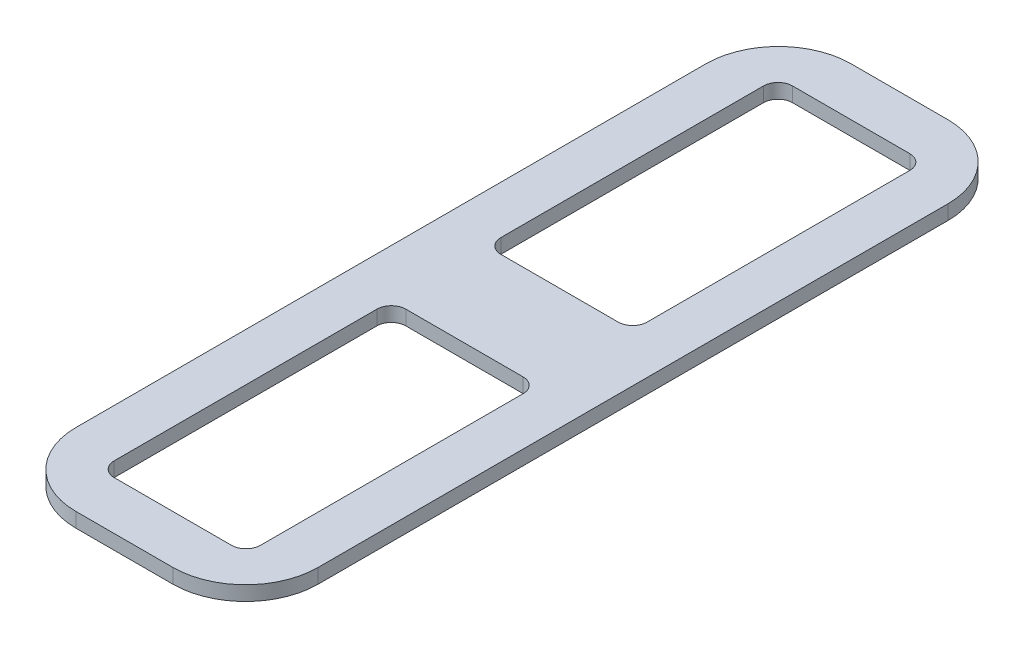
from build123d import *

# Parameters (mm, degrees)
SKETCH1_W           = 50
SKETCH1_H           = 160
BOSS_EXTRUDE1_DEPTH = 3
FILLET2_R           = 15
CUT_EXTRUDE1_DEPTH  = 4


with BuildPart() as part:
    # Sketch1 → Boss-Extrude1 (new body)
    with BuildSketch(Plane(origin=(0, 0, 0), x_dir=(1, 0, 0), z_dir=(0, 1, 0))):
        Rectangle(SKETCH1_W, SKETCH1_H)
    extrude(amount=BOSS_EXTRUDE1_DEPTH)

    # Fillet2
    fillet2_edges = [part.edges().sort_by_distance(p)[0] for p in [
        (25, 1.5, 80),
        (-25, 1.5, 80),
        (-25, 1.5, -80),
        (25, 1.5, -80),
    ]]
    fillet(fillet2_edges, radius=FILLET2_R)

    # Sketch3 → Cut-Extrude1 (cut, through all)
    with BuildSketch(Plane(origin=(0, 3, 0), x_dir=(1, 0, 0), z_dir=(0, 1, 0))):
        with BuildLine():
            Line((-12.1, 70), (12.1, 70))
            ThreePointArc((12.1, 70), (14.221320344, 69.121320344), (15.1, 67))
            Line((15.1, 67), (15.1, 12.8))
            ThreePointArc((15.1, 12.8), (14.221320344, 10.678679656), (12.1, 9.8))
            Line((12.1, 9.8), (-12.1, 9.8))
            ThreePointArc((-12.1, 9.8), (-14.221320344, 10.678679656), (-15.1, 12.8))
            Line((-15.1, 12.8), (-15.1, 67))
            ThreePointArc((-15.1, 67), (-14.221320344, 69.121320344), (-12.1, 70))
        make_face()
    cut_extrude1 = extrude(amount=-CUT_EXTRUDE1_DEPTH, mode=Mode.SUBTRACT)

    # Mirror1: Cut-Extrude1 across plane
    add(cut_extrude1.mirror(Plane.XY), mode=Mode.SUBTRACT)


solid = part.part
